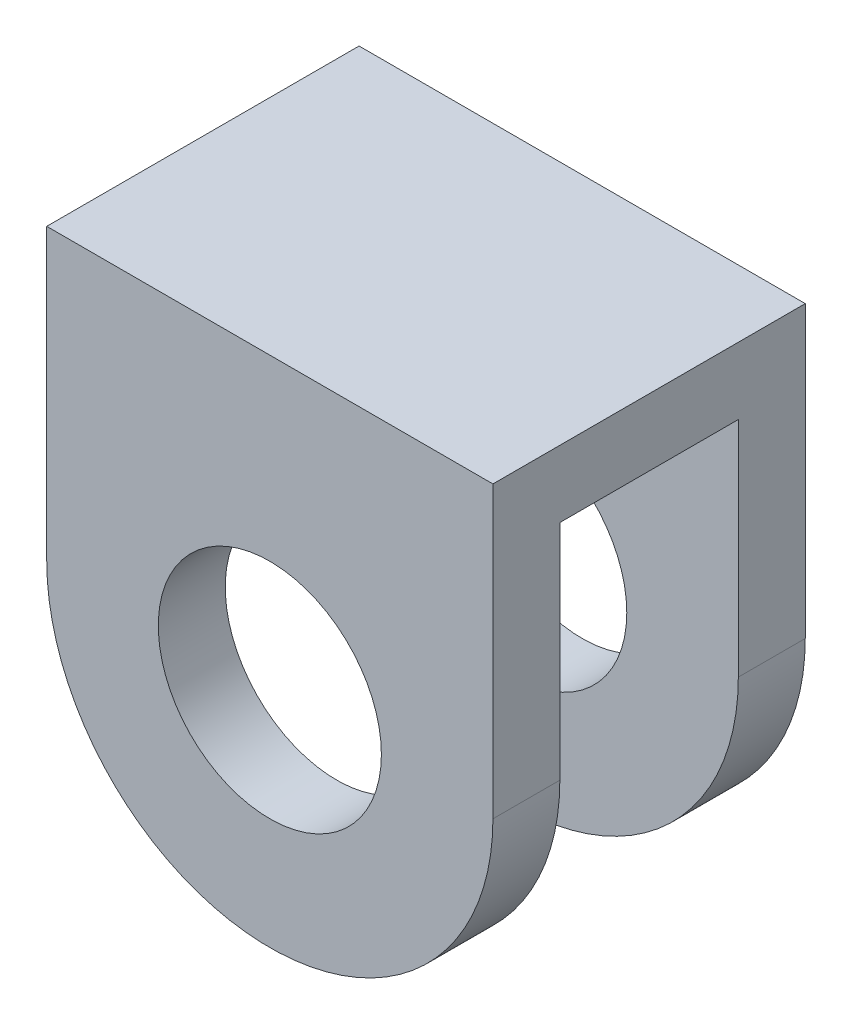
from build123d import *

# Parameters (mm, degrees)
SKETCH_1_R      = 5
EXTRUDE_1_DEPTH = 3
SKETCH_2_W      = 20
SKETCH_2_H      = 14
EXTRUDE_2_DEPTH = 3


with BuildPart() as part:
    # 草图1 → 凸台-拉伸1 (new body)
    with BuildSketch(Plane.XY):
        with BuildLine():
            Line((-35.60315534, 55.522572816), (-15.60315534, 55.522572816))
            Line((-15.60315534, 55.522572816), (-15.60315534, 45.522572816))
            ThreePointArc((-15.60315534, 45.522572816), (-25.60315534, 35.522572816), (-35.60315534, 45.522572816))
            Line((-35.60315534, 45.522572816), (-35.60315534, 55.522572816))
        make_face()
        with Locations((-25.60315534, 45.522572816)):
            Circle(SKETCH_1_R, mode=Mode.SUBTRACT)
    extrude_1 = extrude(amount=EXTRUDE_1_DEPTH)

    # 草图2 → 凸台-拉伸2 (add)
    with BuildSketch(Plane(origin=(0, 55.522572816, 0), x_dir=(1, 0, 0), z_dir=(0, 1, 0))):
        with Locations((-25.60315534, 4)):
            Rectangle(SKETCH_2_W, SKETCH_2_H)
    extrude(amount=EXTRUDE_2_DEPTH)

    # 镜向1: 凸台-拉伸1 across plane
    add(extrude_1.mirror(Plane(origin=(0, 0, -4), x_dir=(1, 0, 0), z_dir=(0, 0, -1))))


solid = part.part
